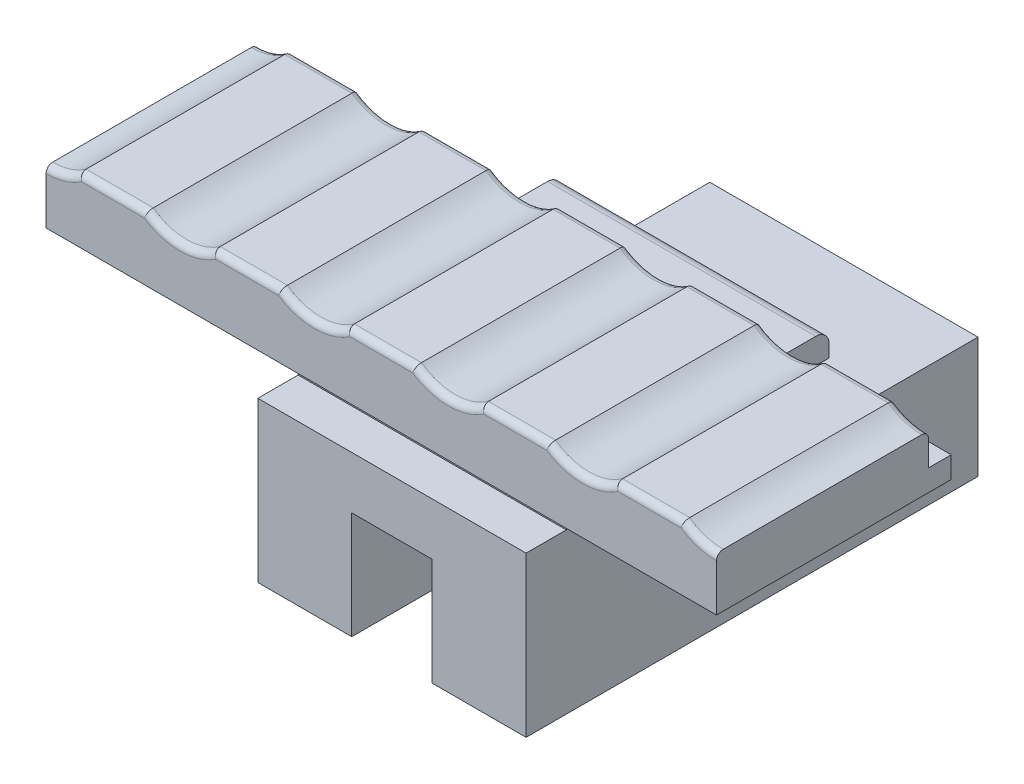
from build123d import *

# Parameters (mm, degrees)
SKETCH1_W            = 25
SKETCH1_H            = 6.85
BOSS_EXTRUDE1_DEPTH  = 0.8
SKETCH2_W            = 10
SKETCH2_H            = 6.85
BOSS_EXTRUDE2_DEPTH  = 3.9
SKETCH3_W            = 3
SKETCH3_H            = 3.85
CUT_EXTRUDE1_DEPTH   = 4.5
BOSS_EXTRUDE3_DEPTH  = 1.5
SKETCH5_W            = 10
SKETCH5_H            = 2.2
BOSS_EXTRUDE4_DEPTH  = 1
SKETCH6_W            = 25
SKETCH6_H            = 0.8
BOSS_EXTRUDE5_DEPTH  = 0.4
SKETCH7_W            = 25
SKETCH7_H            = 7.9
BOSS_EXTRUDE6_DEPTH  = 1.6
SKETCH8_W            = 10
SKETCH8_H            = 0.95
BOSS_EXTRUDE7_DEPTH  = 1.95
SKETCH9_W            = 10
SKETCH9_H            = 0.5
BOSS_EXTRUDE8_DEPTH  = 8.5
SKETCH10_W           = 10
SKETCH10_H           = 1.95
BOSS_EXTRUDE9_DEPTH  = 1.5
SKETCH11_W           = 3.5
SKETCH11_H           = 16.85
BOSS_EXTRUDE10_DEPTH = 4
SKETCH12_W           = 3.5
SKETCH12_H           = 16.85
BOSS_EXTRUDE11_DEPTH = 4
SKETCH13_W           = 2.15
SKETCH13_H           = 7.9
SKETCH14_W           = 7.9
SKETCH14_H           = 2.15
SKETCH15_W           = 2.15
SKETCH15_H           = 7.9
LPATTERN1_COUNT      = 4
LPATTERN1_PITCH      = 5
FILLET1_R            = 0.5
FILLET2_R            = 0.25
FILLET3_R            = 0.25


with BuildPart() as part:
    # Sketch1 → Boss-Extrude1 (new body)
    with BuildSketch(Plane.XZ.offset(4.593725132)):
        with Locations((-3.027595366, 2.575)):
            Rectangle(SKETCH1_W, SKETCH1_H)
    extrude(amount=-BOSS_EXTRUDE1_DEPTH)

    # Sketch2 → Boss-Extrude2 (add)
    with BuildSketch(Plane.XZ.offset(4.593725132)):
        with Locations((-3.027595366, 2.575)):
            Rectangle(SKETCH2_W, SKETCH2_H)
    extrude(amount=BOSS_EXTRUDE2_DEPTH)

    # Sketch3 → Cut-Extrude1 (cut)
    with BuildSketch(Plane.XZ.offset(8.493725132)):
        with Locations((-3.027595366, 2.575)):
            Rectangle(SKETCH3_W, SKETCH3_H)
    extrude(amount=-CUT_EXTRUDE1_DEPTH, mode=Mode.SUBTRACT)

    # Sketch4 → Boss-Extrude3 (add)
    with BuildSketch(Plane.XY.offset(6)):
        with BuildLine():
            Line((0.472404634, -4.593725132), (-6.527595366, -4.593725132))
            ThreePointArc((-6.527595366, -4.593725132), (-7.027595366, -4.890046488), (-7.527595366, -4.593725132))
            Line((-7.527595366, -4.593725132), (-15.527595366, -4.593725132))
            Line((-15.527595366, -4.593725132), (-15.527595366, -3.793725132))
            Line((-15.527595366, -3.793725132), (9.472404634, -3.793725132))
            Line((9.472404634, -3.793725132), (9.472404634, -4.593725132))
            Line((9.472404634, -4.593725132), (1.472404634, -4.593725132))
            ThreePointArc((1.472404634, -4.593725132), (0.972404634, -4.890046488), (0.472404634, -4.593725132))
        make_face()
    extrude(amount=BOSS_EXTRUDE3_DEPTH)

    # Sketch5 → Boss-Extrude4 (add)
    with BuildSketch(Plane(origin=(0, 0, -0.85), x_dir=(-1, 0, 0), z_dir=(0, 0, -1))):
        with Locations((3.027595366, -6.043725132)):
            Rectangle(SKETCH5_W, SKETCH5_H)
    extrude(amount=BOSS_EXTRUDE4_DEPTH)

    # Sketch6 → Boss-Extrude5 (add)
    with BuildSketch(Plane.XY.offset(7.5)):
        with Locations((-3.027595366, -4.193725132)):
            Rectangle(SKETCH6_W, SKETCH6_H)
    extrude(amount=BOSS_EXTRUDE5_DEPTH)

    # Sketch7 → Boss-Extrude6 (add)
    with BuildSketch(Plane(origin=(0, -3.793725132, 0), x_dir=(-1, 0, 0), z_dir=(0, 1, 0))):
        with Locations((3.027595366, 3.95)):
            Rectangle(SKETCH7_W, SKETCH7_H)
    extrude(amount=BOSS_EXTRUDE6_DEPTH)

    # Sketch8 → Boss-Extrude7 (add)
    with BuildSketch(Plane(origin=(0, 0, -1.85), x_dir=(-1, 0, 0), z_dir=(0, 0, -1))):
        with Locations((3.027595366, -5.418725132)):
            Rectangle(SKETCH8_W, SKETCH8_H)
    extrude(amount=BOSS_EXTRUDE7_DEPTH)

    # Sketch9 → Boss-Extrude8 (add)
    with BuildSketch(Plane(origin=(0, 0, -0.85), x_dir=(-1, 0, 0), z_dir=(0, 0, -1))):
        with Locations((3.027595366, -8.243725132)):
            Rectangle(SKETCH9_W, SKETCH9_H)
    extrude(amount=BOSS_EXTRUDE8_DEPTH)

    # Sketch10 → Boss-Extrude9 (add)
    with BuildSketch(Plane.XY.offset(6)):
        with Locations((-3.027595366, -7.518725132)):
            Rectangle(SKETCH10_W, SKETCH10_H)
    extrude(amount=BOSS_EXTRUDE9_DEPTH)

    # Sketch11 → Boss-Extrude10 (add)
    with BuildSketch(Plane.XZ.offset(8.493725132)):
        with Locations((-6.277595366, -0.925)):
            Rectangle(SKETCH11_W, SKETCH11_H)
    extrude(amount=BOSS_EXTRUDE10_DEPTH)

    # Sketch12 → Boss-Extrude11 (add)
    with BuildSketch(Plane.XZ.offset(8.493725132)):
        with Locations((0.222404634, -0.925)):
            Rectangle(SKETCH12_W, SKETCH12_H)
    extrude(amount=BOSS_EXTRUDE11_DEPTH)

    # Sketch13 → Cut-Revolve1 (revolve, cut)
    with BuildSketch(Plane(origin=(-10.497162294, -7.491972288, 0), x_dir=(-0.5809300463626401, 0.8139534883720941, 0), z_dir=(0.8139534883720941, 0.5809300463626401, 0))):
        with Locations((7.584275077, 3.95)):
            Rectangle(SKETCH13_W, SKETCH13_H)
    revolve(axis=Axis((-15.527595366, -0.443725132, 0), (0, 0, 1)), mode=Mode.SUBTRACT)

    # Sketch14 → Cut-Revolve2 (revolve, cut)
    with BuildSketch(Plane(origin=(9.472404634, 0, 0), x_dir=(0, 0, -1), z_dir=(1, 0, 0))):
        with Locations((-3.95, -1.518725132)):
            Rectangle(SKETCH14_W, SKETCH14_H)
    revolve(axis=Axis((9.472404634, -0.443725132, 0), (0, 0, 1)), mode=Mode.SUBTRACT)

    # Sketch15 → Cut-Revolve3 (revolve, cut)
    with BuildSketch(Plane(origin=(-7.184560888, -5.127722099, 0), x_dir=(-0.5809300463626401, 0.8139534883720941, 0), z_dir=(0.8139534883720941, 0.5809300463626401, 0))):
        with Locations((4.679624845, 3.95)):
            Rectangle(SKETCH15_W, SKETCH15_H)
    cut_revolve3 = revolve(axis=Axis((-10.527595366, -0.443725132, 0), (0, 0, 1)), mode=Mode.SUBTRACT)

    # LPattern1: Cut-Revolve3 ×4
    with Locations(*[(i * LPATTERN1_PITCH, 0, 0) for i in range(1, LPATTERN1_COUNT)]):
        add(cut_revolve3, mode=Mode.SUBTRACT)

    # Fillet1
    fillet1_edges = [part.edges().sort_by_distance(p)[0] for p in [
        (-3.027595366, -4.943725132, -3.8),
    ]]
    fillet(fillet1_edges, radius=FILLET1_R)

    # Fillet2
    fillet2_edges = [part.edges().sort_by_distance(p)[0] for p in [
        (-14.871851514, -2.491284655, 0),
        (-13.027595366, -2.193725132, 0),
        (-10.527595366, -2.593725132, 0),
        (-8.027595366, -2.193725132, 0),
        (-5.527595366, -2.593725132, 0),
        (-3.027595366, -2.193725132, 0),
        (-0.527595366, -2.593725132, 0),
        (8.816660781, -2.491284655, 0),
        (1.972404634, -2.193725132, 0),
        (6.972404634, -2.193725132, 0),
        (4.472404634, -2.593725132, 0),
    ]]
    fillet(fillet2_edges, radius=FILLET2_R)

    # Fillet3
    fillet3_edges = [part.edges().sort_by_distance(p)[0] for p in [
        (8.816660781, -2.491284655, 7.9),
        (6.972404634, -2.193725132, 7.9),
        (4.472404634, -2.593725132, 7.9),
        (-14.871851514, -2.491284655, 7.9),
        (1.972404634, -2.193725132, 7.9),
        (-13.027595366, -2.193725132, 7.9),
        (-0.527595366, -2.593725132, 7.9),
        (-10.527595366, -2.593725132, 7.9),
        (-3.027595366, -2.193725132, 7.9),
        (-8.027595366, -2.193725132, 7.9),
        (-5.527595366, -2.593725132, 7.9),
    ]]
    fillet(fillet3_edges, radius=FILLET3_R)


solid = part.part
